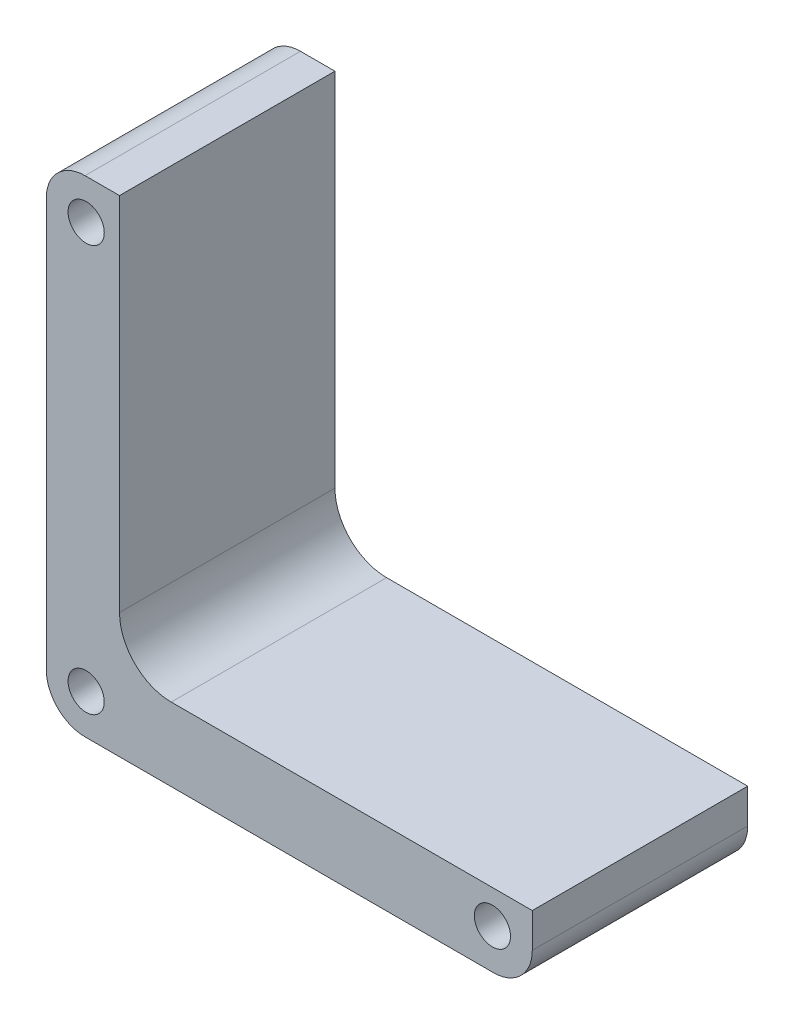
from build123d import *

# Parameters (mm, degrees)
ESQUISSE1_W                               = 56.4
ESQUISSE1_H                               = 56.4
BOSS_EXTRU_1_DEPTH                        = 25
ESQUISSE2_W                               = 75.873546066
ESQUISSE2_H                               = 70.951609501
ENL_V_MAT_EXTRU_1_DEPTH                   = 26
TROU_POUR_TARAUDAGE_POUR_TROU_TARAUD_M5_D = 4.2
CONG_1_R                                  = 6
CONG_2_R                                  = 4.5


with BuildPart() as part:
    # Esquisse1 → Boss.-Extru.1 (new body)
    with BuildSketch(Plane.XY):
        Rectangle(ESQUISSE1_W, ESQUISSE1_H)
    extrude(amount=BOSS_EXTRU_1_DEPTH)

    # Esquisse2 → Enlèv. mat.-Extru.1 (cut, through all)
    with BuildSketch(Plane.XY.offset(25)):
        with Locations((18.236773033, 15.775804751)):
            Rectangle(ESQUISSE2_W, ESQUISSE2_H)
    extrude(amount=-ENL_V_MAT_EXTRU_1_DEPTH, mode=Mode.SUBTRACT)

    # Trou pour taraudage pour trou taraudé M51 (through all)
    with Locations(Plane.XY.offset(25)):
        with Locations((23.57, 23.57), (-23.57, -23.57), (-23.57, 23.57), (23.57, -23.57)):
            Hole(TROU_POUR_TARAUDAGE_POUR_TROU_TARAUD_M5_D / 2)

    # Congé1
    cong_1_edges = [part.edges().sort_by_distance(p)[0] for p in [
        (-19.7, -19.7, 12.5),
    ]]
    fillet(cong_1_edges, radius=CONG_1_R)

    # Congé2
    cong_2_edges = [part.edges().sort_by_distance(p)[0] for p in [
        (28.2, -28.2, 12.5),
        (-28.2, -28.2, 12.5),
        (-28.2, 28.2, 12.5),
    ]]
    fillet(cong_2_edges, radius=CONG_2_R)


solid = part.part
